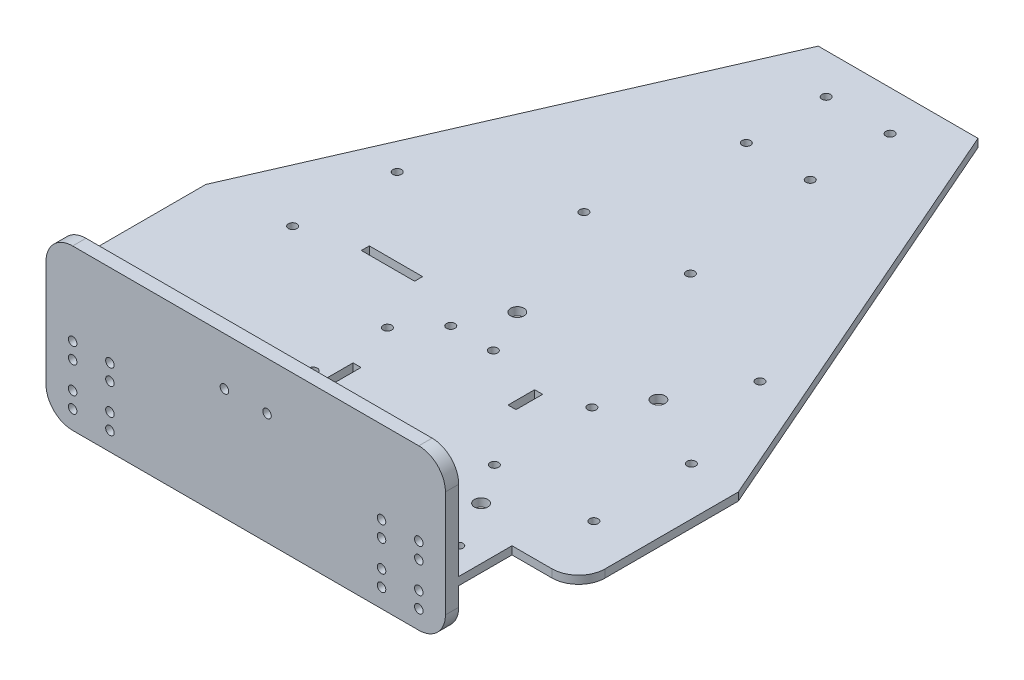
from build123d import *

# Parameters (mm, degrees)
BOSS_EXTRUDE1_DEPTH = 3
SKETCH3_R           = 1.6
SKETCH3_W           = 20
SKETCH3_H           = 3
SKETCH3_W_2         = 3
SKETCH3_H_2         = 10
ARDUINO_DEPTH       = 4
SKETCH6_R           = 1.6
CUT_EXTRUDE4_DEPTH  = 4
SKETCH8_R           = 1.6
CUT_EXTRUDE5_DEPTH  = 10
SKETCH9_R           = 1.6
SKETCH9_R_2         = 2.5
SKETCH9_W           = 3
SKETCH9_H           = 10
L298N_DEPTH         = 10
SKETCH11_W          = 150
SKETCH11_H          = 5
BOSS_EXTRUDE3_DEPTH = 60
FILLET1_R           = 10
SKETCH12_R          = 1.6
CUT_EXTRUDE6_DEPTH  = 10


with BuildPart() as part:
    # Sketch1 → Boss-Extrude1 (new body)
    with BuildSketch(Plane(origin=(0, 0, 0), x_dir=(1, 0, 0), z_dir=(0, 1, 0))):
        with BuildLine():
            Line((100, -40), (100, 10))
            Line((100, 10), (30, 170))
            Line((30, 170), (-30, 170))
            Line((-30, 170), (-100, 10))
            Line((-100, 10), (-100, -40))
            ThreePointArc((-100, -40), (-97.071067812, -47.071067812), (-90, -50))
            Line((-90, -50), (-75, -50))
            Line((-75, -50), (-75, -70))
            Line((-75, -70), (75, -70))
            Line((75, -70), (75, -50))
            Line((75, -50), (90, -50))
            ThreePointArc((90, -50), (97.071067812, -47.071067812), (100, -40))
        make_face()
    extrude(amount=BOSS_EXTRUDE1_DEPTH)

    # Sketch3 → arduino (cut, through all)
    with BuildSketch(Plane(origin=(0, 3, 0), x_dir=(1, 0, 0), z_dir=(0, 1, 0))):
        with Locations((-70.120983048, 12.737637313)):
            Circle(SKETCH3_R)
        with Locations((-71.220983048, -35.062362687)):
            Circle(SKETCH3_R)
        with Locations((-19.320983048, -2.462362687)):
            Circle(SKETCH3_R)
        with Locations((-19.320983048, -30.362362687)):
            Circle(SKETCH3_R)
        with Locations((-39.320983048, -41.562362687)):
            Rectangle(SKETCH3_W, SKETCH3_H)
        with Locations((-39.320983048, 19.237637313)):
            Rectangle(SKETCH3_W, SKETCH3_H)
        with Locations((-12.820983048, -25.362362687)):
            Rectangle(SKETCH3_W_2, SKETCH3_H_2)
    extrude(amount=-ARDUINO_DEPTH, mode=Mode.SUBTRACT)

    # Sketch6 → Cut-Extrude4 (cut, through all)
    with BuildSketch(Plane(origin=(0, 3, 0), x_dir=(1, 0, 0), z_dir=(0, 1, 0))):
        with Locations((12, 155)):
            Circle(SKETCH6_R)
        with Locations((-12, 155)):
            Circle(SKETCH6_R)
        with Locations((12, 125)):
            Circle(SKETCH6_R)
        with Locations((-12, 125)):
            Circle(SKETCH6_R)
    extrude(amount=-CUT_EXTRUDE4_DEPTH, mode=Mode.SUBTRACT)

    # Sketch8 → Cut-Extrude5 (cut)
    with BuildSketch(Plane(origin=(0, 3, 0), x_dir=(1, 0, 0), z_dir=(0, 1, 0))):
        with Locations((8, 10)):
            Circle(SKETCH8_R)
        with Locations((-8, 10)):
            Circle(SKETCH8_R)
        with Locations((-65, -60)):
            Circle(SKETCH8_R)
        with Locations((65, -60)):
            Circle(SKETCH8_R)
    extrude(amount=-CUT_EXTRUDE5_DEPTH, mode=Mode.SUBTRACT)

    # Sketch9 → l298n (cut)
    with BuildSketch(Plane(origin=(0, 3, 0), x_dir=(1, 0, 0), z_dir=(0, 1, 0))):
        with Locations((20, 72)):
            Circle(SKETCH9_R)
        with Locations((-20, 72)):
            Circle(SKETCH9_R)
        with Locations((45, 10)):
            Circle(SKETCH9_R)
        with Locations((81.998174007, 10.367586933)):
            Circle(SKETCH9_R)
        with Locations((82.36576094, -26.630587074)):
            Circle(SKETCH9_R)
        with Locations((45.367586933, -26.998174007)):
            Circle(SKETCH9_R)
        with Locations((-68.125, 50)):
            Circle(SKETCH9_R)
        with Locations((68.125, 50)):
            Circle(SKETCH9_R)
        with Locations((55, 25)):
            Circle(SKETCH9_R_2)
        with Locations((55.367586933, -41.998174007)):
            Circle(SKETCH9_R_2)
        with Locations((0, 27)):
            Circle(SKETCH9_R_2)
        with Locations((30, 0)):
            Rectangle(SKETCH9_W, SKETCH9_H)
    extrude(amount=-L298N_DEPTH, mode=Mode.SUBTRACT)

    # Sketch11 → Boss-Extrude3 (add)
    with BuildSketch(Plane(origin=(0, 43, 0), x_dir=(1, 0, 0), z_dir=(0, 1, 0))):
        with Locations((0, -72.5)):
            Rectangle(SKETCH11_W, SKETCH11_H)
    extrude(amount=-BOSS_EXTRUDE3_DEPTH)

    # Fillet1
    fillet1_edges = [part.edges().sort_by_distance(p)[0] for p in [
        (-75, -17, 72.5),
        (75, -17, 72.5),
        (-75, 43, 72.5),
        (75, 43, 72.5),
    ]]
    fillet(fillet1_edges, radius=FILLET1_R)

    # Sketch12 → Cut-Extrude6 (cut)
    with BuildSketch(Plane.XY.offset(75)):
        with Locations((-65, -10)):
            Circle(SKETCH12_R)
        with Locations((-51, -10)):
            Circle(SKETCH12_R)
        with Locations((-65, -4)):
            Circle(SKETCH12_R)
        with Locations((-65, 6)):
            Circle(SKETCH12_R)
        with Locations((-65, 12)):
            Circle(SKETCH12_R)
        with Locations((-51, 12)):
            Circle(SKETCH12_R)
        with Locations((-51, 6)):
            Circle(SKETCH12_R)
        with Locations((-51, -4)):
            Circle(SKETCH12_R)
        with Locations((51, -10)):
            Circle(SKETCH12_R)
        with Locations((65, -10)):
            Circle(SKETCH12_R)
        with Locations((51, -4)):
            Circle(SKETCH12_R)
        with Locations((51, 6)):
            Circle(SKETCH12_R)
        with Locations((51, 12)):
            Circle(SKETCH12_R)
        with Locations((65, -4)):
            Circle(SKETCH12_R)
        with Locations((65, 6)):
            Circle(SKETCH12_R)
        with Locations((65, 12)):
            Circle(SKETCH12_R)
        with Locations((-8, 25)):
            Circle(SKETCH12_R)
        with Locations((8, 25)):
            Circle(SKETCH12_R)
    extrude(amount=-CUT_EXTRUDE6_DEPTH, mode=Mode.SUBTRACT)


solid = part.part
